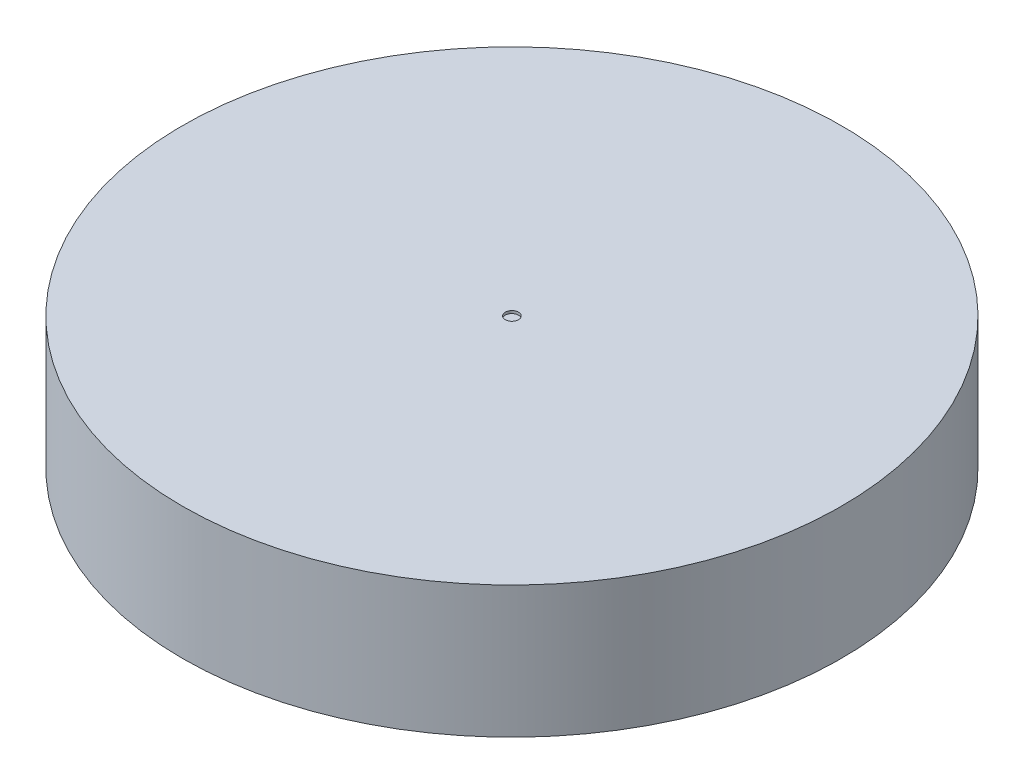
from build123d import *

# Parameters (mm, degrees)
ESBO_O1_R                = 25
RESSALTO_EXTRUS_O1_DEPTH = 10
ESBO_O2_W                = 2.5
ESBO_O2_H                = 5.2
ESBO_O2_W_2              = 5.2
ESBO_O2_H_2              = 2.5
CORTE_EXTRUS_O1_DEPTH    = 6
ESBO_O3_R                = 0.5
CORTE_EXTRUS_O2_DEPTH    = 0.2


with BuildPart() as part:
    # Esboço1 → Ressalto-extrusão1 (new body)
    with BuildSketch(Plane(origin=(0, 0, 0), x_dir=(1, 0, 0), z_dir=(0, 1, 0))):
        Circle(ESBO_O1_R)
    extrude(amount=RESSALTO_EXTRUS_O1_DEPTH)

    # Esboço2 → Corte-extrusão1 (cut)
    with BuildSketch(Plane.XZ):
        with Locations((-3.85, 0)):
            Rectangle(ESBO_O2_W, ESBO_O2_H)
        Rectangle(ESBO_O2_W_2, ESBO_O2_H)
        with Locations((0, 3.85)):
            Rectangle(ESBO_O2_W_2, ESBO_O2_H_2)
        with Locations((3.85, 0)):
            Rectangle(ESBO_O2_W, ESBO_O2_H)
        with Locations((0, -3.85)):
            Rectangle(ESBO_O2_W_2, ESBO_O2_H_2)
    extrude(amount=-CORTE_EXTRUS_O1_DEPTH, mode=Mode.SUBTRACT)

    # Esboço3 → Corte-extrusão2 (cut)
    with BuildSketch(Plane(origin=(0, 10, 0), x_dir=(1, 0, 0), z_dir=(0, 1, 0))):
        Circle(ESBO_O3_R)
    extrude(amount=-CORTE_EXTRUS_O2_DEPTH, mode=Mode.SUBTRACT)


solid = part.part
